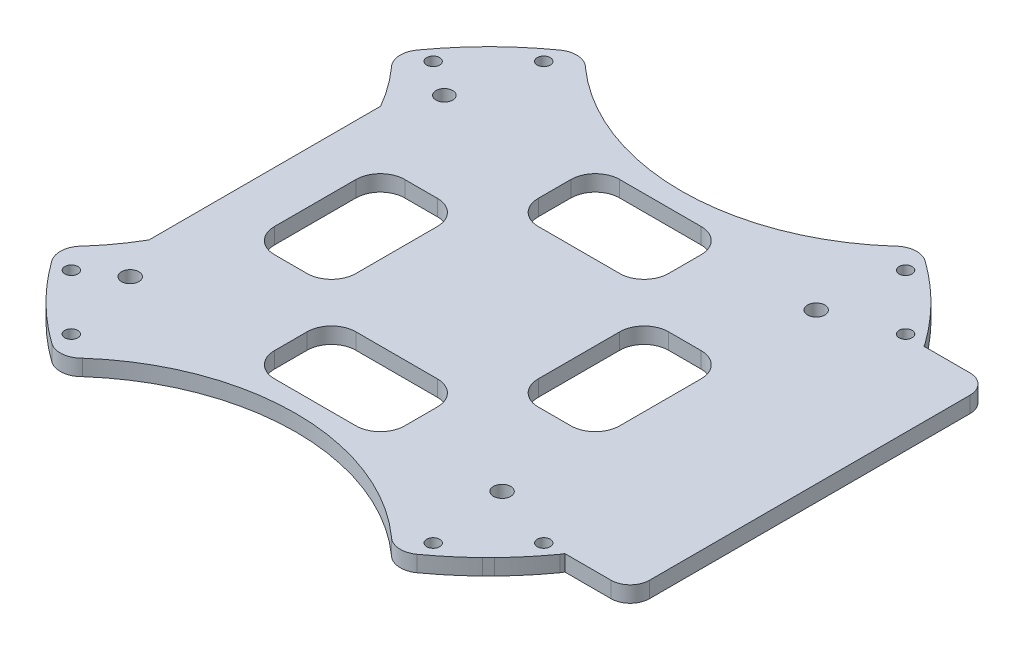
from build123d import *

# Parameters (mm, degrees)
SKETCH_4_R          = 1.015999997
EXTRUDE_1_DEPTH     = 2.5
SKETCH_1_R          = 1.35
SKETCH_1_R_2        = 1.3
CUT_EXTRUDE_1_DEPTH = 2.5
CUT_EXTRUDE_2_DEPTH = 2.5


with BuildPart() as part:
    # 草图4 → 凸台-拉伸1 (new body)
    with BuildSketch(Plane(origin=(0, 0, 0), x_dir=(1, 0, 0), z_dir=(0, 1, 0))):
        with BuildLine():
            Line((-42.436188428, 34.195477543), (-41.49137262, 35.131555803))
            ThreePointArc((-41.49137262, 35.131555803), (-38.877647905, 37.476008525), (-36.102115814, 39.626458957))
            ThreePointArc((-36.102115814, 39.626458957), (-33.841762455, 40.245239062), (-31.726243819, 39.236939987))
            ThreePointArc((-31.726243819, 39.236939987), (-7.620828088, 30.054645119), (16.484587642, 39.236939987))
            ThreePointArc((16.484587642, 39.236939987), (18.600106279, 40.245239062), (20.860459637, 39.626458957))
            ThreePointArc((20.860459637, 39.626458957), (23.705991726, 37.417514086), (26.38082366, 35.004680806))
            Line((26.38082366, 35.004680806), (27.30697313, 34.080620624))
            ThreePointArc((27.30697313, 34.080620624), (29.761287419, 31.369052268), (32.005630869, 28.481287726))
            ThreePointArc((32.005630869, 28.481287726), (32.159827034, 28.246667313), (32.293910707, 28))
            Line((32.293910707, 28), (39.5, 28))
            ThreePointArc((39.5, 28), (41.621320344, 27.121320344), (42.5, 25))
            Line((42.5, 25), (42.5, -25))
            ThreePointArc((42.5, -25), (41.621320344, -27.121320344), (39.5, -28))
            Line((39.5, -28), (32.293910707, -28))
            ThreePointArc((32.293910707, -28), (32.159827034, -28.246667313), (32.005630869, -28.481287726))
            ThreePointArc((32.005630869, -28.481287726), (29.775946345, -31.351575111), (27.338818851, -34.047952742))
            Line((27.338818851, -34.047952742), (26.411119263, -34.975227797))
            ThreePointArc((26.411119263, -34.975227797), (23.722187526, -37.403948618), (20.860459637, -39.626458957))
            ThreePointArc((20.860459637, -39.626458957), (18.600106279, -40.245239062), (16.484587642, -39.236939987))
            ThreePointArc((16.484587642, -39.236939987), (-7.620828088, -30.054645119), (-31.726243819, -39.236939987))
            ThreePointArc((-31.726243819, -39.236939987), (-33.841762455, -40.245239062), (-36.102115814, -39.626458957))
            ThreePointArc((-36.102115814, -39.626458957), (-39.084675426, -37.302363339), (-41.878340415, -34.754321303))
            Line((-41.878340415, -34.754321303), (-42.799522233, -33.821583024))
            ThreePointArc((-42.799522233, -33.821583024), (-45.118593637, -31.230715312), (-47.247287045, -28.481287726))
            ThreePointArc((-47.247287045, -28.481287726), (-47.86606715, -26.220934367), (-46.857768075, -24.105415731))
            ThreePointArc((-46.857768075, -24.105415731), (-44.523235736, -21.197270026), (-42.5, -18.064560362))
            Line((-42.5, -18.064560362), (-42.5, 18.064560362))
            ThreePointArc((-42.5, 18.064560362), (-44.523235736, 21.197270026), (-46.857768075, 24.105415731))
            ThreePointArc((-46.857768075, 24.105415731), (-47.86606715, 26.220934367), (-47.247287045, 28.481287726))
            ThreePointArc((-47.247287045, 28.481287726), (-44.951232672, 31.430572594), (-42.436188428, 34.195477543))
        make_face()
        with Locations((20.59934216, 36.841216125)):
            Circle(SKETCH_4_R, mode=Mode.SUBTRACT)
        with Locations((29.220388037, 28.220170249)):
            Circle(SKETCH_4_R, mode=Mode.SUBTRACT)
        with Locations((29.220388037, -28.220170249)):
            Circle(SKETCH_4_R, mode=Mode.SUBTRACT)
        with Locations((20.59934216, -36.841216125)):
            Circle(SKETCH_4_R, mode=Mode.SUBTRACT)
        with Locations((-35.840998337, -36.841216125)):
            Circle(SKETCH_4_R, mode=Mode.SUBTRACT)
        with Locations((-44.462044213, -28.220170249)):
            Circle(SKETCH_4_R, mode=Mode.SUBTRACT)
        with Locations((-35.840998337, 36.841216125)):
            Circle(SKETCH_4_R, mode=Mode.SUBTRACT)
        with Locations((-44.462044213, 28.220170249)):
            Circle(SKETCH_4_R, mode=Mode.SUBTRACT)
    extrude(amount=EXTRUDE_1_DEPTH)

    # 草图1 → 切除-拉伸1 (cut)
    with BuildSketch(Plane(origin=(0, 0, 0), x_dir=(1, 0, 0), z_dir=(0, 1, 0))):
        with Locations((19, -24.5)):
            Circle(SKETCH_1_R)
        with Locations((19, 24.5)):
            Circle(SKETCH_1_R)
        with Locations((-39, -24.5)):
            Circle(SKETCH_1_R)
        with Locations((-39, 24.5)):
            Circle(SKETCH_1_R_2)
    extrude(amount=CUT_EXTRUDE_1_DEPTH, mode=Mode.SUBTRACT)

    # 草图7 → 切除-拉伸2 (cut)
    with BuildSketch(Plane(origin=(0, 2.5, 0), x_dir=(1, 0, 0), z_dir=(0, 1, 0))):
        with BuildLine():
            Line((-1.255512377, -27.041509959), (-13.955512377, -27.041509959))
            ThreePointArc((-13.955512377, -27.041509959), (-16.649589213, -25.925586795), (-17.765512377, -23.231509959))
            Line((-17.765512377, -23.231509959), (-17.765512377, -18.151509959))
            ThreePointArc((-17.765512377, -18.151509959), (-16.649589213, -15.457433122), (-13.955512377, -14.341509959))
            Line((-13.955512377, -14.341509959), (-1.255512377, -14.341509959))
            ThreePointArc((-1.255512377, -14.341509959), (1.43856446, -15.457433122), (2.554487623, -18.151509959))
            Line((2.554487623, -18.151509959), (2.554487623, -23.231509959))
            ThreePointArc((2.554487623, -23.231509959), (1.43856446, -25.925586795), (-1.255512377, -27.041509959))
        make_face()
        with BuildLine():
            Line((6.618487623, -6.467509959), (6.618487623, 6.232490041))
            ThreePointArc((6.618487623, 6.232490041), (7.734410787, 8.926566878), (10.428487623, 10.042490041))
            Line((10.428487623, 10.042490041), (15.508487623, 10.042490041))
            ThreePointArc((15.508487623, 10.042490041), (18.20256446, 8.926566878), (19.318487623, 6.232490041))
            Line((19.318487623, 6.232490041), (19.318487623, -6.467509959))
            ThreePointArc((19.318487623, -6.467509959), (18.20256446, -9.161586795), (15.508487623, -10.277509959))
            Line((15.508487623, -10.277509959), (10.428487623, -10.277509959))
            ThreePointArc((10.428487623, -10.277509959), (7.734410787, -9.161586795), (6.618487623, -6.467509959))
        make_face()
        with BuildLine():
            Line((-1.255512377, 14.106490041), (-13.955512377, 14.106490041))
            ThreePointArc((-13.955512377, 14.106490041), (-16.649589213, 15.222413205), (-17.765512377, 17.916490041))
            Line((-17.765512377, 17.916490041), (-17.765512377, 22.996490041))
            ThreePointArc((-17.765512377, 22.996490041), (-16.649589213, 25.690566878), (-13.955512377, 26.806490041))
            Line((-13.955512377, 26.806490041), (-1.255512377, 26.806490041))
            ThreePointArc((-1.255512377, 26.806490041), (1.43856446, 25.690566878), (2.554487623, 22.996490041))
            Line((2.554487623, 22.996490041), (2.554487623, 17.916490041))
            ThreePointArc((2.554487623, 17.916490041), (1.43856446, 15.222413205), (-1.255512377, 14.106490041))
        make_face()
        with BuildLine():
            Line((-25.639512377, -10.277509959), (-30.719512377, -10.277509959))
            ThreePointArc((-30.719512377, -10.277509959), (-33.413589213, -9.161586795), (-34.529512377, -6.467509959))
            Line((-34.529512377, -6.467509959), (-34.529512377, 6.232490041))
            ThreePointArc((-34.529512377, 6.232490041), (-33.413589213, 8.926566878), (-30.719512377, 10.042490041))
            Line((-30.719512377, 10.042490041), (-25.639512377, 10.042490041))
            ThreePointArc((-25.639512377, 10.042490041), (-22.94543554, 8.926566878), (-21.829512377, 6.232490041))
            Line((-21.829512377, 6.232490041), (-21.829512377, -6.467509959))
            ThreePointArc((-21.829512377, -6.467509959), (-22.94543554, -9.161586795), (-25.639512377, -10.277509959))
        make_face()
    extrude(amount=-CUT_EXTRUDE_2_DEPTH, mode=Mode.SUBTRACT)


solid = part.part
